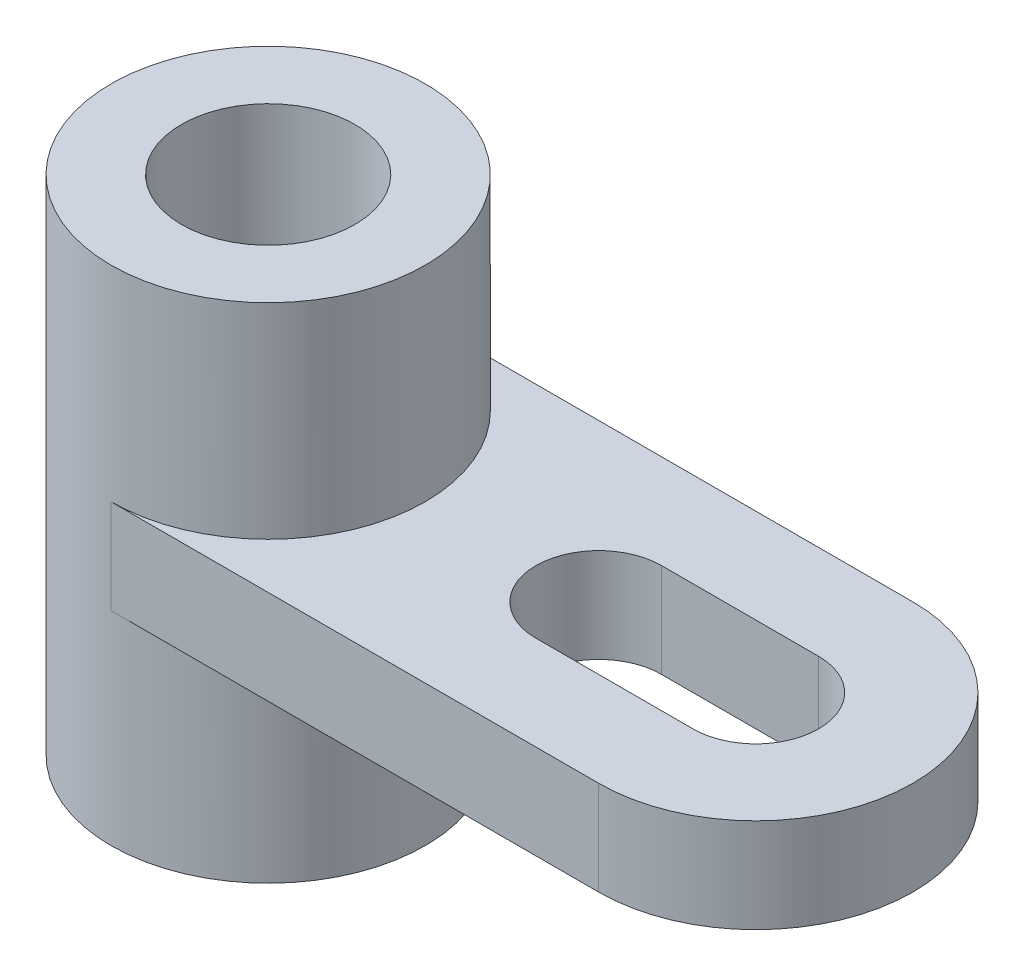
from build123d import *

# Parameters (mm, degrees)
BOSS_EXTRUDE1_DEPTH      = 19.05
CUT_EXTRUDE3_DEPTH       = 20.05
SKETCH3_R                = 31.75
BOSS_EXTRUDE2_DEPTH      = 41.402
BOSS_EXTRUDE2_DEPTH_BACK = 60.198
SKETCH4_R                = 17.526
CUT_EXTRUDE2_DEPTH       = 102.6


with BuildPart() as part:
    # Sketch1 → Boss-Extrude1 (new body)
    with BuildSketch(Plane(origin=(0, 0, 0), x_dir=(1, 0, 0), z_dir=(0, 1, 0))):
        with BuildLine():
            Line((-49.276, 31.75), (49.276, 31.75))
            ThreePointArc((49.276, 31.75), (81.026, 0), (49.276, -31.75))
            Line((49.276, -31.75), (-49.276, -31.75))
            ThreePointArc((-49.276, -31.75), (-81.026, 0), (-49.276, 31.75))
        make_face()
    extrude(amount=BOSS_EXTRUDE1_DEPTH)

    # Sketch5 → Cut-Extrude3 (cut, through all)
    with BuildSketch(Plane.XZ):
        with BuildLine():
            Line((17.526, 12.7), (49.276, 12.7))
            ThreePointArc((49.276, 12.7), (61.976, 0), (49.276, -12.7))
            Line((49.276, -12.7), (17.526, -12.7))
            ThreePointArc((17.526, -12.7), (4.826, 0), (17.526, 12.7))
        make_face()
    extrude(amount=-CUT_EXTRUDE3_DEPTH, mode=Mode.SUBTRACT)

    # Sketch3 → Boss-Extrude2 (add, two sides)
    with BuildSketch(Plane(origin=(0, 19.05, 0), x_dir=(1, 0, 0), z_dir=(0, 1, 0))) as boss_extrude2_sk:
        with Locations(Location((-49.276, 0, 0), (0, 0, 270))):  # turned: the seam where the file's is
            Circle(SKETCH3_R)
    extrude(amount=BOSS_EXTRUDE2_DEPTH)
    extrude(boss_extrude2_sk.sketch, amount=-BOSS_EXTRUDE2_DEPTH_BACK)

    # Sketch4 → Cut-Extrude2 (cut, through all)
    with BuildSketch(Plane(origin=(0, 60.452, 0), x_dir=(1, 0, 0), z_dir=(0, 1, 0))):
        with Locations(Location((-49.276, 0, 0), (0, 0, 270))):  # turned: the seam where the file's is
            Circle(SKETCH4_R)
    extrude(amount=-CUT_EXTRUDE2_DEPTH, mode=Mode.SUBTRACT)


solid = part.part
